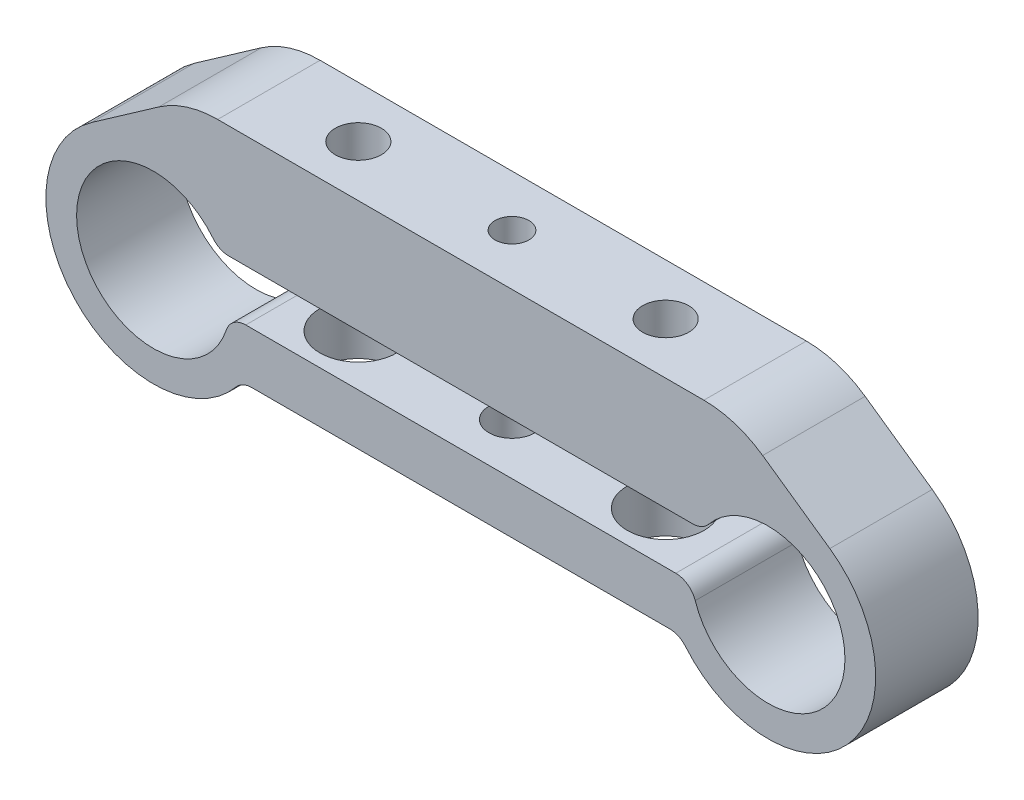
from build123d import *

# Parameters (mm, degrees)
EXTRUDE_1_DEPTH       = 10
CUT_EXTRUDE_1_REACH   = 23
SKETCH_3_R            = 3.75
HOLE_WIZARD_M41_D     = 4.5
HOLE_WIZARD_M42_D     = 4.5
HOLE_WIZARD_M42_DEPTH = 5
M4X0_71_D             = 3.3
FILLET_1_R            = 10
FILLET_2_R            = 2


with BuildPart() as part:
    # Эскиз1 → Бобышка-Вытянуть1 (new body)
    with BuildSketch(Plane.XY):
        with BuildLine():
            Line((-26.883971253, 15), (26.883971253, 15))
            Line((26.883971253, 15), (36.022552582, 8.601096465))
            ThreePointArc((36.022552582, 8.601096465), (37.414889847, -7.43433982), (21.38315603, -6))
            Line((21.38315603, -6), (-21.38315603, -6))
            ThreePointArc((-21.38315603, -6), (-37.414889847, -7.43433982), (-36.022552582, 8.601096465))
            Line((-36.022552582, 8.601096465), (-26.883971253, 15))
        make_face()
        with BuildLine():
            Line((-23.65571123, 4), (23.65571123, 4))
            ThreePointArc((23.65571123, 4), (37.328277987, -1.595726088), (22.566965626, -1))
            Line((22.566965626, -1), (-22.566965626, -1))
            ThreePointArc((-22.566965626, -1), (-37.328277987, -1.595726088), (-23.65571123, 4))
        make_face(mode=Mode.SUBTRACT)
    extrude(amount=EXTRUDE_1_DEPTH)

    # Эскиз3 → Вырез-Вытянуть1 (cut, up to next)
    with BuildSketch(Plane.XZ.offset(6), mode=Mode.PRIVATE) as cut_extrude_1_sk1:
        with Locations((-15, 5)):
            Circle(SKETCH_3_R)
    cut_extrude_1_tool1 = extrude(cut_extrude_1_sk1.sketch, amount=-CUT_EXTRUDE_1_REACH, mode=Mode.PRIVATE) & part.part
    add(cut_extrude_1_tool1.solids().sort_by_distance((-15, -6, 5))[0], mode=Mode.SUBTRACT)
    # Эскиз3 → Вырез-Вытянуть1 (cut, up to next)
    with BuildSketch(Plane.XZ.offset(6), mode=Mode.PRIVATE) as cut_extrude_1_sk2:
        with Locations((15, 5)):
            Circle(SKETCH_3_R)
    cut_extrude_1_tool2 = extrude(cut_extrude_1_sk2.sketch, amount=-CUT_EXTRUDE_1_REACH, mode=Mode.PRIVATE) & part.part
    add(cut_extrude_1_tool2.solids().sort_by_distance((15, -6, 5))[0], mode=Mode.SUBTRACT)

    # Отверстие с зазором M41 (through all)
    with Locations(Plane(origin=(0, 4, 0), x_dir=(-1, 0, 0), z_dir=(0, -1, 0))):
        with Locations((-15, -5), (15, -5)):
            Hole(HOLE_WIZARD_M41_D / 2)

    # Отверстие с зазором M42
    with Locations(Plane(origin=(0, -6, 0), x_dir=(-1, 0, 0), z_dir=(0, -1, 0))):
        with Locations((0, -5)):
            Hole(HOLE_WIZARD_M42_D / 2, depth=HOLE_WIZARD_M42_DEPTH)

    # Отверстие обработанное метчиком M4x0.71 (through all)
    with Locations(Plane(origin=(0, 4, 0), x_dir=(-1, 0, 0), z_dir=(0, -1, 0))):
        with Locations((0, -5)):
            Hole(M4X0_71_D / 2)

    # Скругление1
    fillet_1_edges = [part.edges().sort_by_distance(p)[0] for p in [
        (-26.883971253, 15, 5),
        (26.883971253, 15, 5),
    ]]
    fillet(fillet_1_edges, radius=FILLET_1_R)

    # Скругление2
    fillet_2_edges = [part.edges().sort_by_distance(p)[0] for p in [
        (21.38315603, -6, 5),
        (-21.38315603, -6, 5),
        (-23.65571123, 4, 5),
        (-22.566965626, -1, 5),
        (22.566965626, -1, 5),
        (23.65571123, 4, 5),
    ]]
    fillet(fillet_2_edges, radius=FILLET_2_R)


solid = part.part
